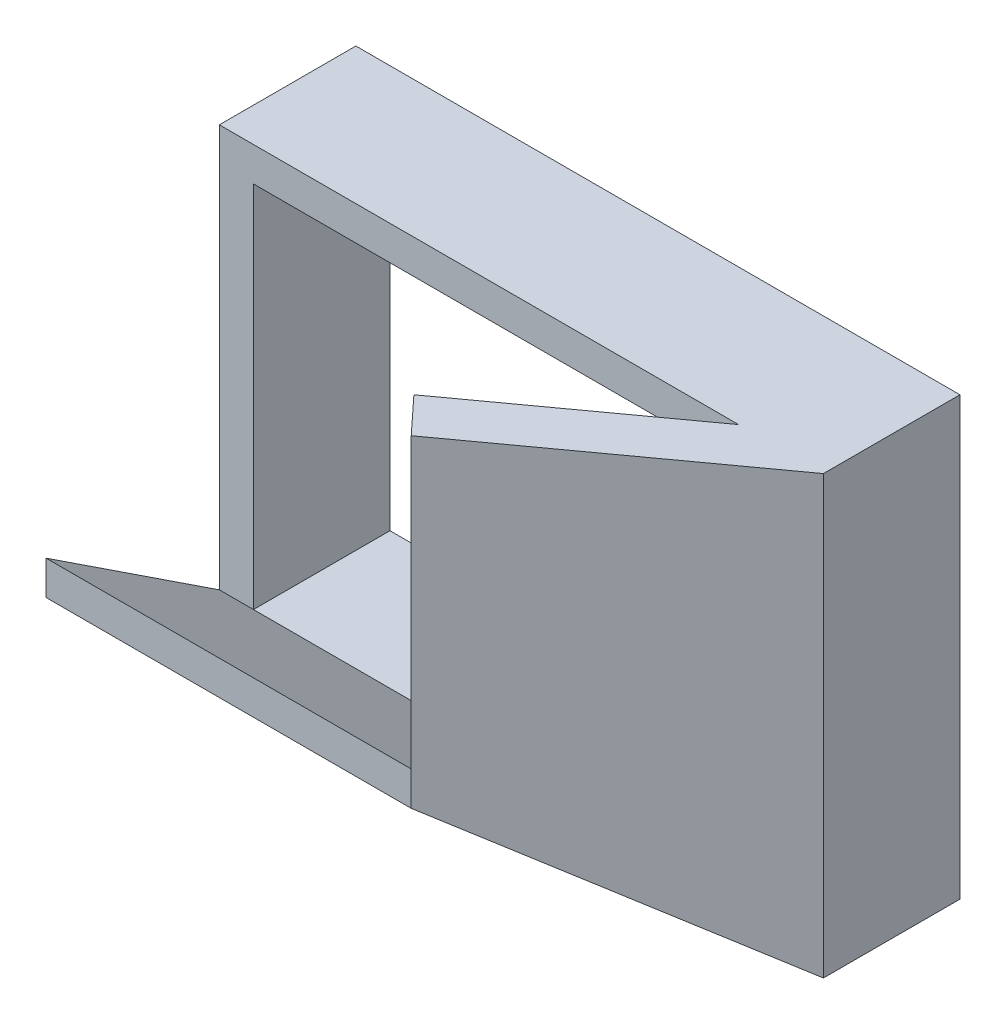
from build123d import *

# Parameters (mm, degrees)
SKETCH1_W           = 17.7
SKETCH1_H           = 12.8
SKETCH1_W_2         = 15.7
SKETCH1_H_2         = 10.8
BOSS_EXTRUDE1_DEPTH = 4
BOSS_EXTRUDE2_DEPTH = 12.8
BOSS_EXTRUDE3_DEPTH = 17.7
CUT_EXTRUDE1_DEPTH  = 18.7
CUT_EXTRUDE3_REACH  = 19.7


with BuildPart() as part:
    # Sketch1 → Boss-Extrude1 (new body)
    with BuildSketch(Plane.XY):
        with Locations((-17.55, -7.7)):
            Rectangle(SKETCH1_W, SKETCH1_H)
        with Locations((-17.55, -7.7)):
            Rectangle(SKETCH1_W_2, SKETCH1_H_2, mode=Mode.SUBTRACT)
    extrude(amount=-BOSS_EXTRUDE1_DEPTH)

    # Sketch7 → Boss-Extrude2 (add)
    with BuildSketch(Plane.XZ.offset(14.1)):
        Polygon((-8.7, 0), (-15.7, 5.077748715), (-16.7, 4), (-9.7, -1.077748715), align=None)
    extrude(amount=-BOSS_EXTRUDE2_DEPTH)

    # Sketch11 → Boss-Extrude3 (add)
    with BuildSketch(Plane(origin=(-8.7, 0, -8.7), x_dir=(0, 0, 1), z_dir=(1, 0, 0))):
        Polygon((8.7, 13.1), (8.7, 14.1), (13.777748715, 10.756920169), (13.777748715, 9.756920169), align=None)
    extrude(amount=-BOSS_EXTRUDE3_DEPTH)

    # Sketch13 → Cut-Extrude1 (cut, through all)
    with BuildSketch(Plane(origin=(-8.7, 0, 0), x_dir=(0, 0, -1), z_dir=(1, 0, 0))):
        Polygon((-5.077748715, -10.756920169), (-5.077748715, -15.295870945), (0, -14.1), align=None)
    extrude(amount=-CUT_EXTRUDE1_DEPTH, mode=Mode.SUBTRACT)

    # Cut-Extrude3: up to this face of the body (flat: up to its plane)
    cut_extrude3_end = Plane(part.part.faces().sort_by_distance((-12.007460376, -6.410206852, 2.399207524))[0])
    # Sketch11_3 → Cut-Extrude3 (cut, up to the picked face)
    with BuildSketch(Plane(origin=(-8.7, 0, -8.7), x_dir=(0, 0, 1), z_dir=(1, 0, 0)), mode=Mode.PRIVATE) as cut_extrude3_sk1:
        Polygon((8.7, 13.1), (8.7, 14.1), (13.777748715, 10.756920169), (13.777748715, 9.756920169), align=None)
    cut_extrude3_tool1 = split(extrude(cut_extrude3_sk1.sketch, amount=-CUT_EXTRUDE3_REACH, mode=Mode.PRIVATE), bisect_by=cut_extrude3_end, keep=Keep.BOTH, mode=Mode.PRIVATE)
    add(cut_extrude3_tool1.solids().sort_by_distance((-8.7, -11.92846, 2.538874))[0], mode=Mode.SUBTRACT)


solid = part.part
